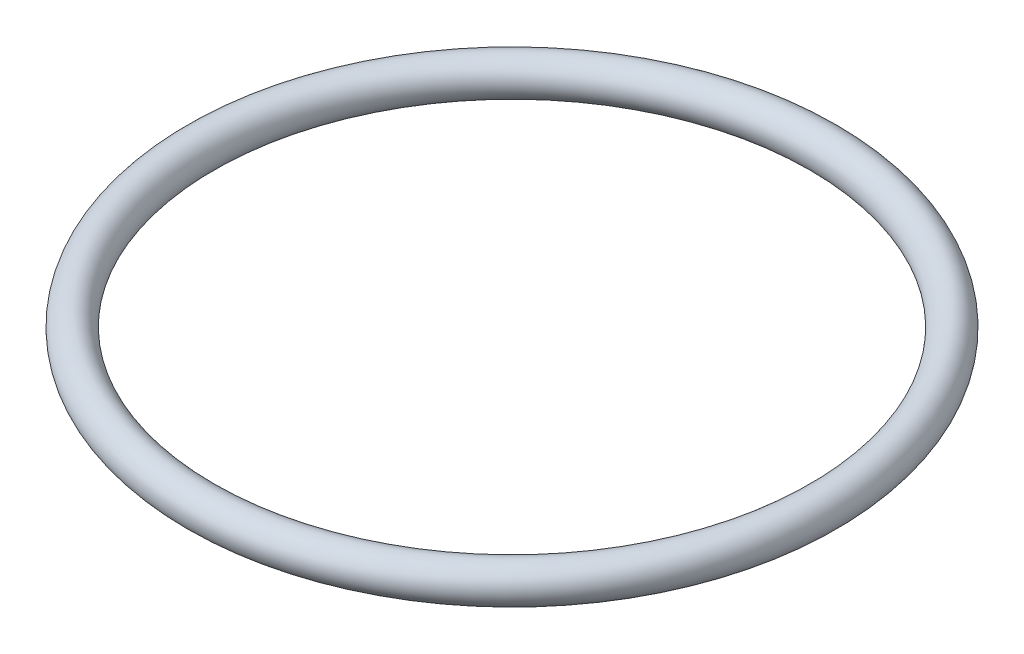
from build123d import *

# Parameters (mm, degrees)
SKETCH1_R = 2.5908


with BuildPart() as part:
    # Sketch1 → Revolve1 (revolve)
    with BuildSketch(Plane.XY):
        with Locations((-43.5102, 0)):
            Circle(SKETCH1_R)
    revolve(axis=Axis((0, 0, 0), (0, 1, 0)))


solid = part.part
